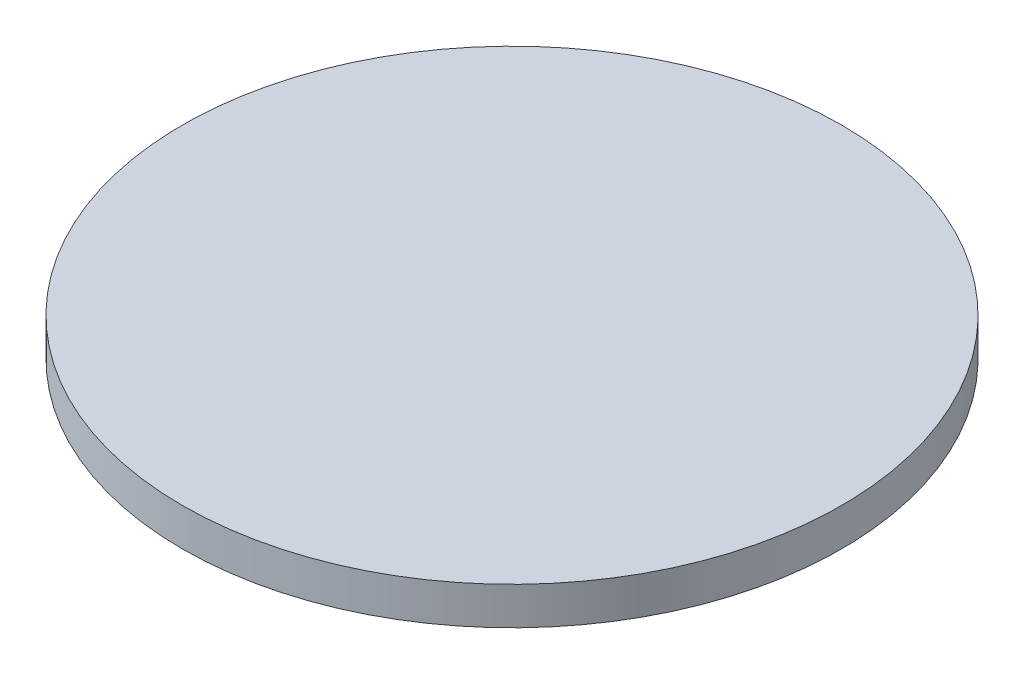
from build123d import *

# Parameters (mm, degrees)
SKETCH3_R           = 175
BOSS_EXTRUDE1_DEPTH = 20
SKETCH4_R           = 70
CUT_EXTRUDE1_DEPTH  = 10


with BuildPart() as part:
    # Sketch3 → Boss-Extrude1 (new body)
    with BuildSketch(Plane(origin=(0, 0, 0), x_dir=(1, 0, 0), z_dir=(0, 1, 0))):
        Circle(SKETCH3_R)
    extrude(amount=BOSS_EXTRUDE1_DEPTH)

    # Sketch4 → Cut-Extrude1 (cut)
    with BuildSketch(Plane.XZ):
        Circle(SKETCH4_R)
    extrude(amount=-CUT_EXTRUDE1_DEPTH, mode=Mode.SUBTRACT)


solid = part.part
